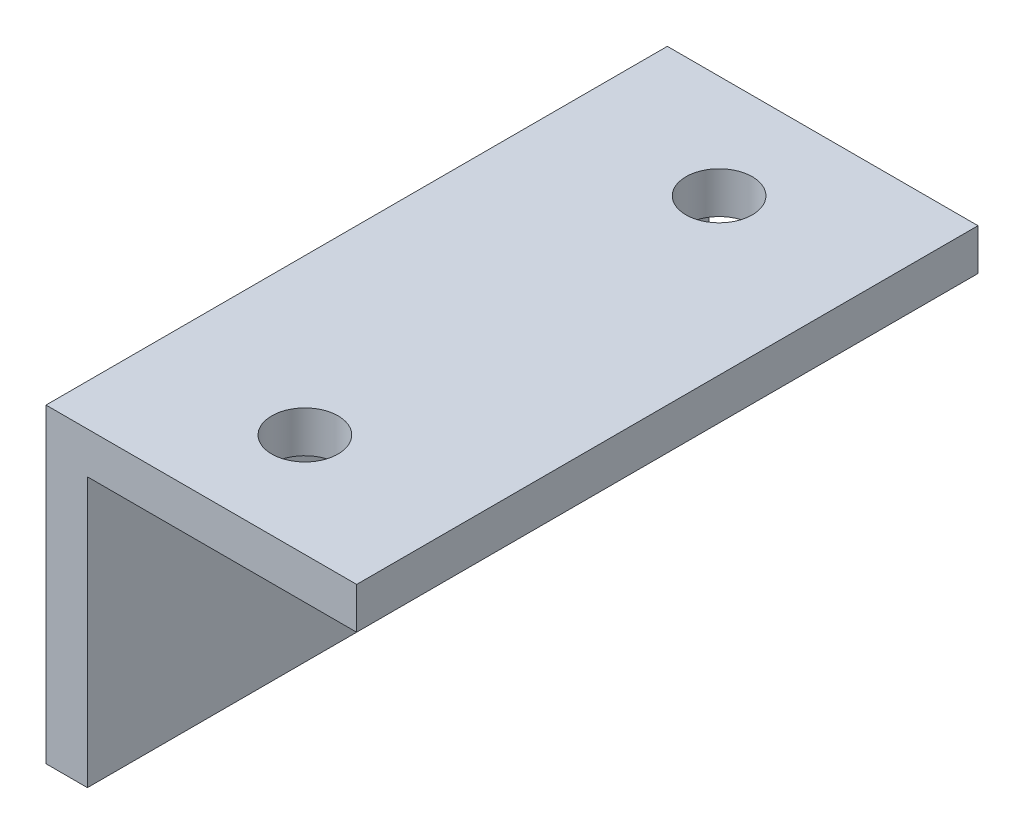
from build123d import *

# Parameters (mm, degrees)
EXTRUDE_1_DEPTH     = 30
SKETCH_2_R          = 1.6
CUT_EXTRUDE_1_DEPTH = 30
SKETCH_3_R          = 2.1
CUT_EXTRUDE_2_DEPTH = 30


with BuildPart() as part:
    # ｽｹｯﾁ1 → ﾎﾞｽ - 押し出し1 (new body)
    with BuildSketch(Plane.XY):
        Polygon((0, 0), (0, -15), (2, -15), (2, -2), (15, -2), (15, 0), align=None)
    extrude(amount=EXTRUDE_1_DEPTH)

    # ｽｹｯﾁ2 → ｶｯﾄ - 押し出し1 (cut)
    with BuildSketch(Plane(origin=(0, 0, 0), x_dir=(1, 0, 0), z_dir=(0, 1, 0))):
        with Locations((7.5, -5)):
            Circle(SKETCH_2_R)
        with Locations((7.5, -25)):
            Circle(SKETCH_2_R)
    extrude(amount=-CUT_EXTRUDE_1_DEPTH, mode=Mode.SUBTRACT)

    # ｽｹｯﾁ3 → ｶｯﾄ - 押し出し2 (cut)
    with BuildSketch(Plane.ZY):
        with Locations((15, -9)):
            Circle(SKETCH_3_R)
    extrude(amount=-CUT_EXTRUDE_2_DEPTH, mode=Mode.SUBTRACT)


solid = part.part
